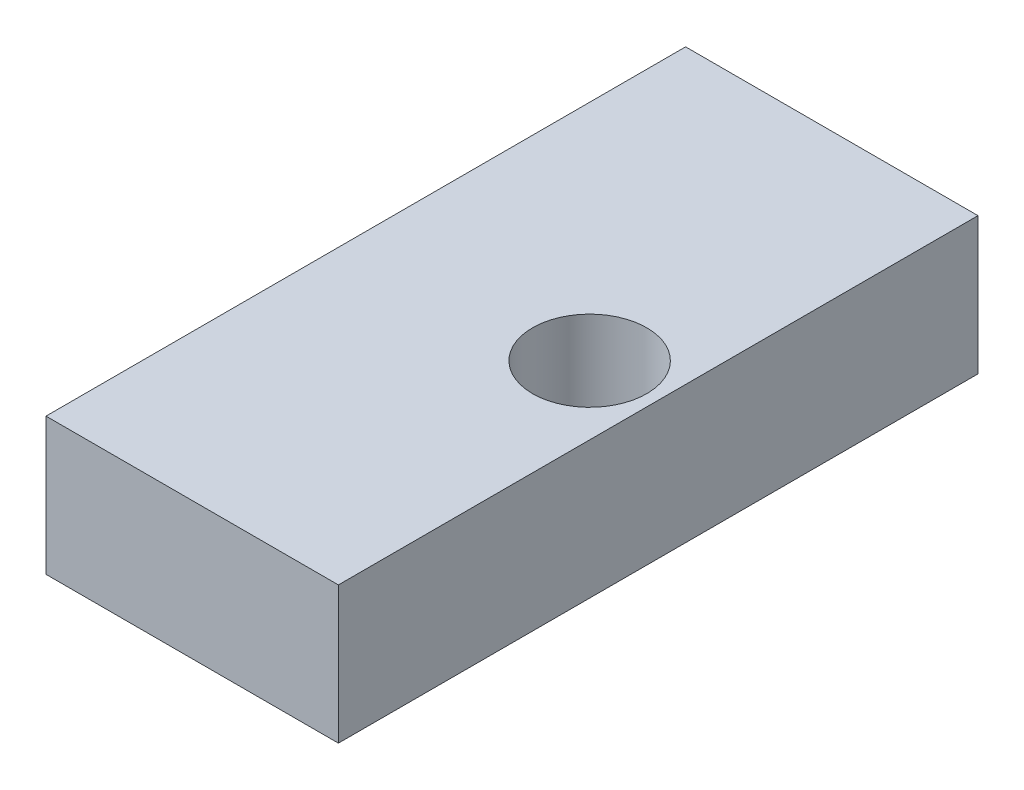
from build123d import *

# Parameters (mm, degrees)
SKETCH1_W           = 40.64
SKETCH1_H           = 19.05
BOSS_EXTRUDE1_DEPTH = 88.9
SKETCH3_R           = 7.9375
CUT_EXTRUDE1_DEPTH  = 20.05


with BuildPart() as part:
    # Sketch1 → Boss-Extrude1 (new body)
    with BuildSketch(Plane.XY):
        Rectangle(SKETCH1_W, SKETCH1_H)
    extrude(amount=-BOSS_EXTRUDE1_DEPTH)

    # Sketch3 → Cut-Extrude1 (cut, through all)
    with BuildSketch(Plane(origin=(0, 9.525, 0), x_dir=(1, 0, 0), z_dir=(0, 1, 0))):
        with Locations((10.795, 44.45)):
            Circle(SKETCH3_R)
    extrude(amount=-CUT_EXTRUDE1_DEPTH, mode=Mode.SUBTRACT)


solid = part.part
